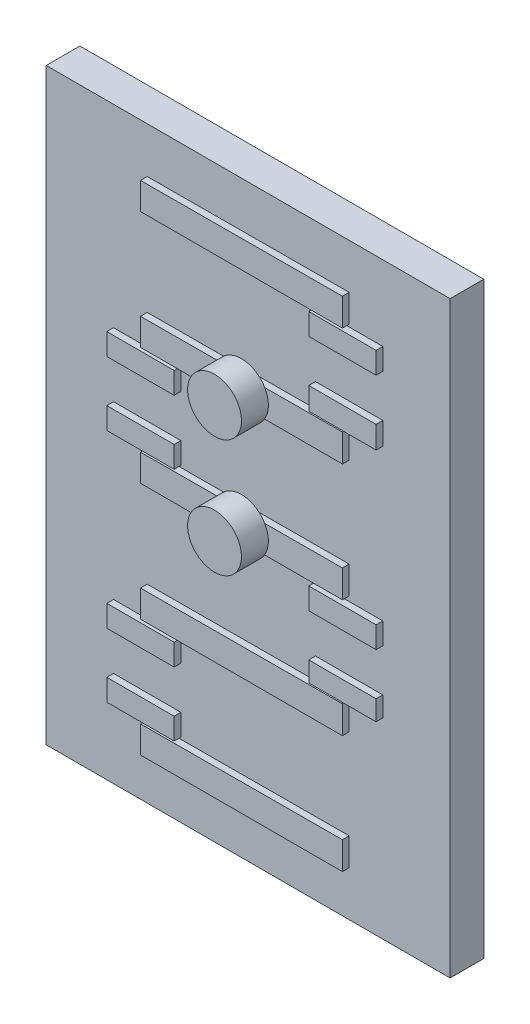
from build123d import *

# Parameters (mm, degrees)
SKETCH1_W             = 19.05
SKETCH1_H             = 27.7495
BOSS_EXTRUDE1_DEPTH   = 1.5875
F_0_80_TAPPED_HOLE1_D = 1.19126
SKETCH4_W             = 3.175
SKETCH4_H             = 0.9398
SKETCH4_H_2           = 1.016
SKETCH4_H_3           = 1.050029844
BOSS_EXTRUDE2_DEPTH   = 0.3175
BOSS_EXTRUDE3_DEPTH   = 0.3175
LPATTERN1_COUNT       = 5
LPATTERN1_PITCH       = 5.5499
SKETCH8_R             = 1.27
BOSS_EXTRUDE4_DEPTH   = 1.27


with BuildPart() as part:
    # Sketch1 → Boss-Extrude1 (new body)
    with BuildSketch(Plane.XY):
        Rectangle(SKETCH1_W, SKETCH1_H)
    extrude(amount=BOSS_EXTRUDE1_DEPTH)

    # #0-80 Tapped Hole1 (through all)
    with Locations(Plane.XY.offset(1.5875)):
        with Locations((0, -11.0998), (0, -5.5499), (0, 0), (0, 5.5499), (0, 11.0998)):
            Hole(F_0_80_TAPPED_HOLE1_D / 2)

    # Sketch4 → Boss-Extrude2 (add)
    with BuildSketch(Plane.XY.offset(1.5875)):
        with Locations((4.7625, -4.3688)):
            Rectangle(SKETCH4_W, SKETCH4_H)
        with Locations((-4.7625, -9.8806)):
            Rectangle(SKETCH4_W, SKETCH4_H_2)
        with Locations((-4.7625, -6.858)):
            Rectangle(SKETCH4_W, SKETCH4_H_2)
        with Locations((4.7625, -1.3843)):
            Rectangle(SKETCH4_W, SKETCH4_H_2)
        with Locations((-4.7625, 1.2192)):
            Rectangle(SKETCH4_W, SKETCH4_H_2)
        with Locations((-4.7625, 4.2418)):
            Rectangle(SKETCH4_W, SKETCH4_H_2)
        with Locations((4.7625, 6.786114922)):
            Rectangle(SKETCH4_W, SKETCH4_H_3)
        with Locations((4.7625, 9.825729844)):
            Rectangle(SKETCH4_W, SKETCH4_H_2)
    extrude(amount=BOSS_EXTRUDE2_DEPTH)

    # Sketch6 → Boss-Extrude3 (add)
    with BuildSketch(Plane.XY.offset(1.5875)):
        Polygon((4.7625, -10.447923864), (-4.7625, -10.481668166), (-4.7625, -11.751668166), (4.7625, -11.751668166), align=None)
    boss_extrude3 = extrude(amount=BOSS_EXTRUDE3_DEPTH)

    # LPattern1: Boss-Extrude3 ×5
    with Locations(*[(0, i * LPATTERN1_PITCH, 0) for i in range(1, LPATTERN1_COUNT)]):
        add(boss_extrude3)

    # Sketch8 → Boss-Extrude4 (add)
    with BuildSketch(Plane.XY.offset(1.905)):
        Circle(SKETCH8_R)
        with Locations((0, 5.5499)):
            Circle(SKETCH8_R)
    extrude(amount=BOSS_EXTRUDE4_DEPTH)


solid = part.part
